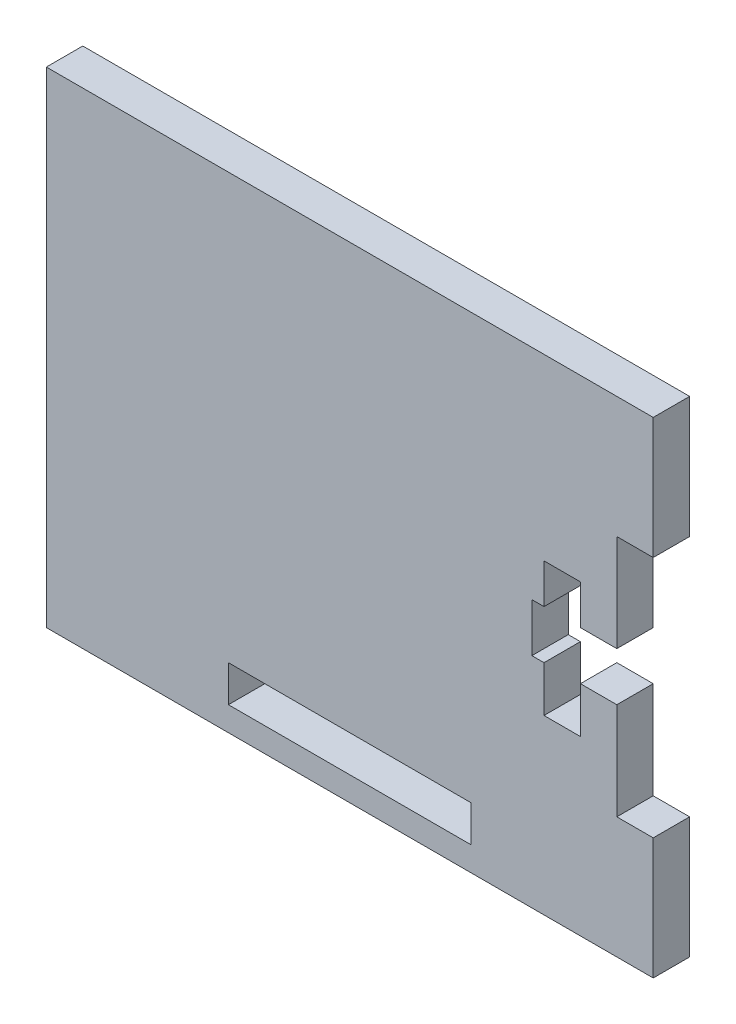
from build123d import *

# Parameters (mm, degrees)
SKETCH_1_W      = 20
SKETCH_1_H      = 3
EXTRUDE_1_DEPTH = 1.5


with BuildPart() as part:
    # 草图1 → 凸台-拉伸1 (new body, symmetric)
    with BuildSketch(Plane.XY):
        Polygon((-25, 20), (25, 20), (25, 10), (22, 10), (22, 2), (19, 2), (19, 5.265909841), (16, 5.265909841), (16, 2), (15, 2), (15, -2), (16, -2), (16, -5.769694942), (19, -5.769694942), (19, -2), (22, -2), (22, -10), (25, -10), (25, -20), (-25, -20), align=None)
        with Locations((0, -16.5)):
            Rectangle(SKETCH_1_W, SKETCH_1_H, mode=Mode.SUBTRACT)
    extrude(amount=EXTRUDE_1_DEPTH, both=True)


solid = part.part
